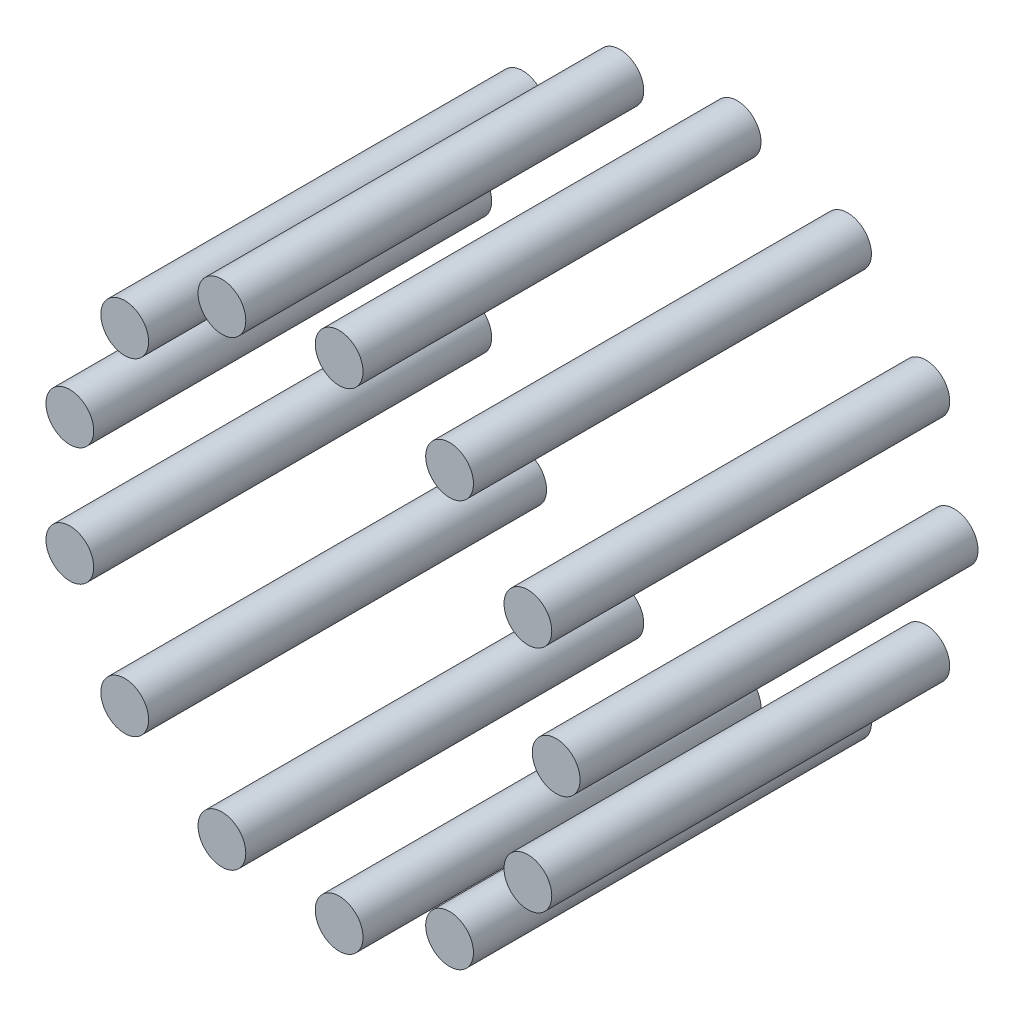
from build123d import *

# Parameters (mm, degrees)
SKETCH1_R              = 3
BOSS_EXTRUDE1_DEPTH    = 50
BOSS_EXTRUDE1_2_DEPTH  = 50
BOSS_EXTRUDE1_3_DEPTH  = 50
BOSS_EXTRUDE1_4_DEPTH  = 50
BOSS_EXTRUDE1_5_DEPTH  = 50
BOSS_EXTRUDE1_6_DEPTH  = 50
BOSS_EXTRUDE1_7_DEPTH  = 50
BOSS_EXTRUDE1_8_DEPTH  = 50
BOSS_EXTRUDE1_9_DEPTH  = 50
BOSS_EXTRUDE1_10_DEPTH = 50
BOSS_EXTRUDE1_11_DEPTH = 50
BOSS_EXTRUDE1_12_DEPTH = 50
BOSS_EXTRUDE1_13_DEPTH = 50


with BuildPart() as part:
    # Sketch1 → Boss-Extrude1 (new body)
    with BuildSketch(Plane.XY):
        with Locations((31, 0)):
            Circle(SKETCH1_R)
    extrude(amount=BOSS_EXTRUDE1_DEPTH)


with BuildPart() as body_2:
    # Sketch1 → Boss-Extrude1 2 (new body)
    with BuildSketch(Plane.XY):
        with Locations((27.449136795, -14.406418333)):
            Circle(SKETCH1_R)
    extrude(amount=BOSS_EXTRUDE1_2_DEPTH)


with BuildPart() as body_3:
    # Sketch1 → Boss-Extrude1 3 (new body)
    with BuildSketch(Plane.XY):
        with Locations((17.610007149, -25.512499843)):
            Circle(SKETCH1_R)
    extrude(amount=BOSS_EXTRUDE1_3_DEPTH)


with BuildPart() as body_4:
    # Sketch1 → Boss-Extrude1 4 (new body)
    with BuildSketch(Plane.XY):
        with Locations((3.736637088, -30.773975097)):
            Circle(SKETCH1_R)
    extrude(amount=BOSS_EXTRUDE1_4_DEPTH)


with BuildPart() as body_5:
    # Sketch1 → Boss-Extrude1 5 (new body)
    with BuildSketch(Plane.XY):
        with Locations((-10.992751498, -28.985503523)):
            Circle(SKETCH1_R)
    extrude(amount=BOSS_EXTRUDE1_5_DEPTH)


with BuildPart() as body_6:
    # Sketch1 → Boss-Extrude1 6 (new body)
    with BuildSketch(Plane.XY):
        with Locations((-23.203833193, -20.556802405)):
            Circle(SKETCH1_R)
    extrude(amount=BOSS_EXTRUDE1_6_DEPTH)


with BuildPart() as body_7:
    # Sketch1 → Boss-Extrude1 7 (new body)
    with BuildSketch(Plane.XY):
        with Locations((-30.09919634, -7.418785593)):
            Circle(SKETCH1_R)
    extrude(amount=BOSS_EXTRUDE1_7_DEPTH)


with BuildPart() as body_8:
    # Sketch1 → Boss-Extrude1 8 (new body)
    with BuildSketch(Plane.XY):
        with Locations((-30.09919634, 7.418785593)):
            Circle(SKETCH1_R)
    extrude(amount=BOSS_EXTRUDE1_8_DEPTH)


with BuildPart() as body_9:
    # Sketch1 → Boss-Extrude1 9 (new body)
    with BuildSketch(Plane.XY):
        with Locations((-23.203833193, 20.556802405)):
            Circle(SKETCH1_R)
    extrude(amount=BOSS_EXTRUDE1_9_DEPTH)


with BuildPart() as body_10:
    # Sketch1 → Boss-Extrude1 10 (new body)
    with BuildSketch(Plane.XY):
        with Locations((-10.992751498, 28.985503523)):
            Circle(SKETCH1_R)
    extrude(amount=BOSS_EXTRUDE1_10_DEPTH)


with BuildPart() as body_11:
    # Sketch1 → Boss-Extrude1 11 (new body)
    with BuildSketch(Plane.XY):
        with Locations((3.736637088, 30.773975097)):
            Circle(SKETCH1_R)
    extrude(amount=BOSS_EXTRUDE1_11_DEPTH)


with BuildPart() as body_12:
    # Sketch1 → Boss-Extrude1 12 (new body)
    with BuildSketch(Plane.XY):
        with Locations((17.610007149, 25.512499843)):
            Circle(SKETCH1_R)
    extrude(amount=BOSS_EXTRUDE1_12_DEPTH)


with BuildPart() as body_13:
    # Sketch1 → Boss-Extrude1 13 (new body)
    with BuildSketch(Plane.XY):
        with Locations((27.449136795, 14.406418333)):
            Circle(SKETCH1_R)
    extrude(amount=BOSS_EXTRUDE1_13_DEPTH)


solid = Compound([part.part, body_2.part, body_3.part, body_4.part, body_5.part, body_6.part, body_7.part, body_8.part, body_9.part, body_10.part, body_11.part, body_12.part, body_13.part])
